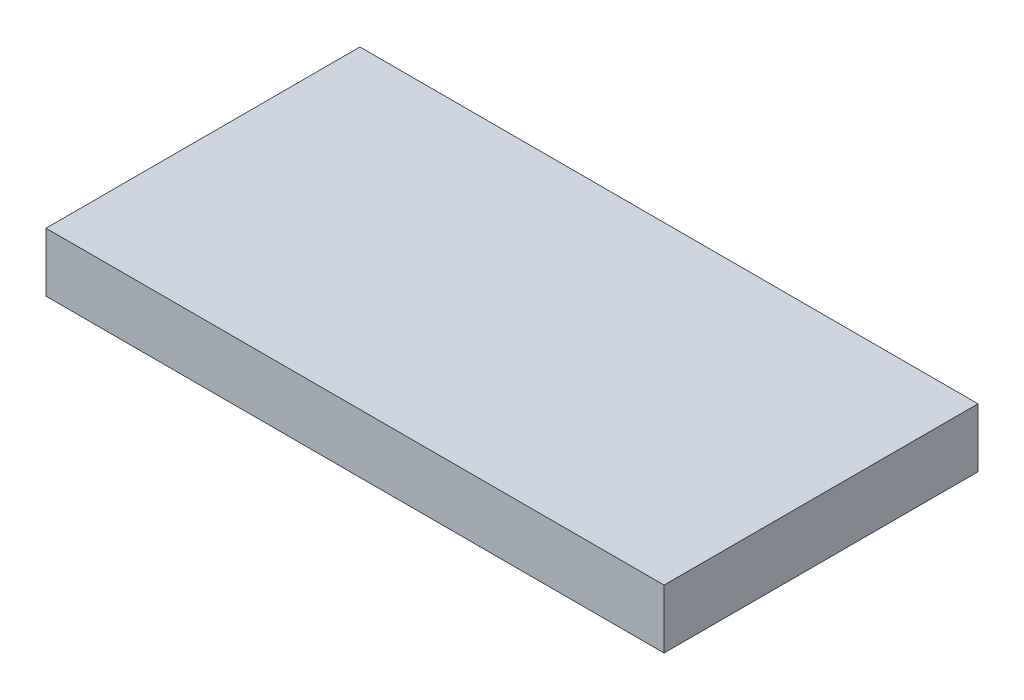
from build123d import *

# Parameters (mm, degrees)
SKETCH1_W           = 5.1
SKETCH1_H           = 3.2
SKETCH1_W_2         = 0.6
BOSS_EXTRUDE1_DEPTH = 0.3


with BuildPart() as part:
    # Sketch1 → Boss-Extrude1 (new body, symmetric)
    with BuildSketch(Plane(origin=(0, 0, 0), x_dir=(1, 0, 0), z_dir=(0, 1, 0))):
        Rectangle(SKETCH1_W, SKETCH1_H)
        with Locations((-2.85, 0)):
            Rectangle(SKETCH1_W_2, SKETCH1_H)
        with Locations((2.85, 0)):
            Rectangle(SKETCH1_W_2, SKETCH1_H)
    extrude(amount=BOSS_EXTRUDE1_DEPTH, both=True)


solid = part.part
